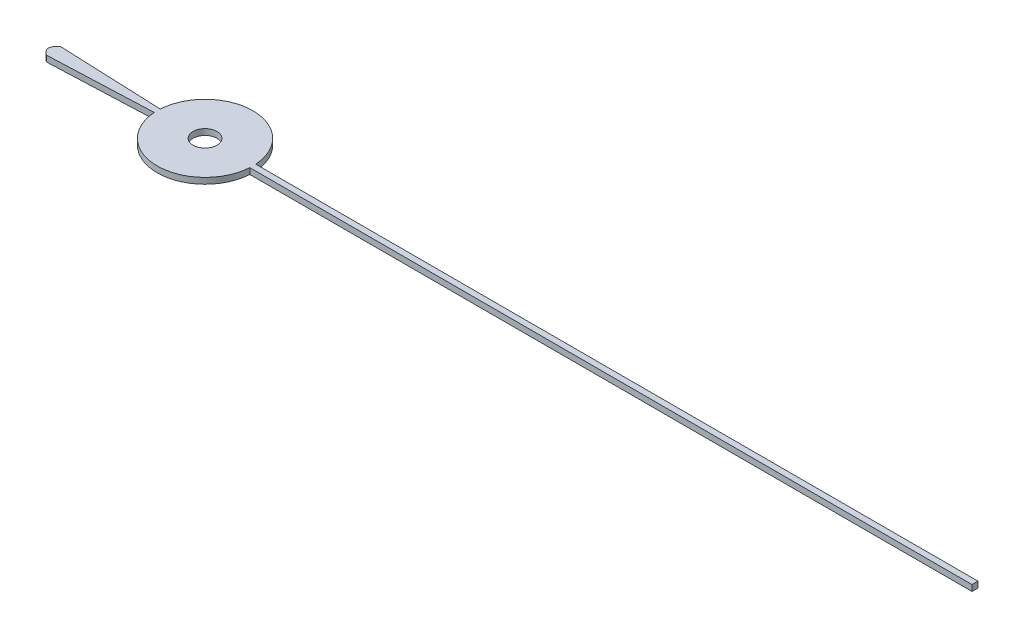
from build123d import *

# Parameters (mm, degrees)
BOSS_EXTRUDE2_DEPTH = 0.5
SKETCH3_R           = 1
CUT_EXTRUDE2_DEPTH  = 1.5000001


with BuildPart() as part:
    # Sketch1 → Boss-Extrude2 (new body)
    with BuildSketch(Plane(origin=(0, 0, 0), x_dir=(1, 0, 0), z_dir=(0, 1, 0))):
        with BuildLine():
            Line((64.487313154, 0.25), (4, 0.25))
            ThreePointArc((4, 0.25), (0, 4.007804885), (-4, 0.25))
            Line((-4, 0.25), (-12.67773598, 0.606260641))
            add(Edge.make_bspline(
                [(-12.67773598, -0.606260641), (-13.533789945, 0), (-12.67773598, 0.606260641)],
                knots=[0, 0, 0, 1, 1, 1], degree=2))
            Line((-12.67773598, -0.606260641), (-4, -0.25))
            ThreePointArc((-4, -0.25), (0, -4.007804885), (4, -0.25))
            Line((4, -0.25), (64.487313154, -0.25))
            Line((64.487313154, -0.25), (64.487313154, 0.25))
        make_face()
    extrude(amount=BOSS_EXTRUDE2_DEPTH)

    # Sketch3 → Cut-Extrude2 (cut, through all)
    with BuildSketch(Plane(origin=(0, 0.5, 0), x_dir=(1, 0, 0), z_dir=(0, 1, 0))):
        Circle(SKETCH3_R)
    extrude(amount=-CUT_EXTRUDE2_DEPTH, mode=Mode.SUBTRACT)


solid = part.part
